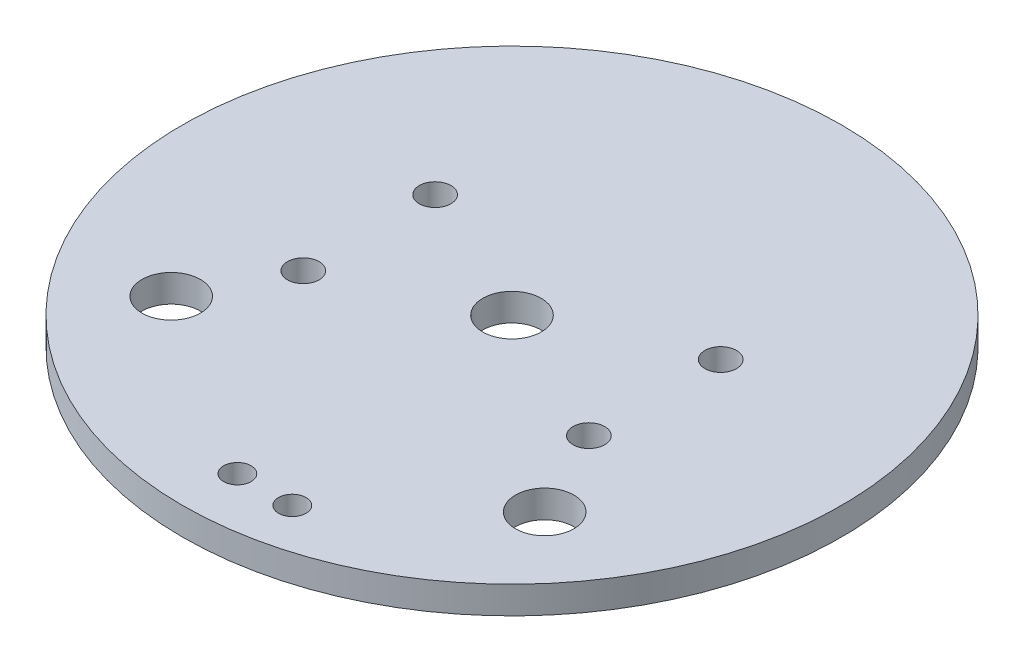
from build123d import *

# Parameters (mm, degrees)
SKETCH1_R                    = 38.1
BOSS_EXTRUDE1_DEPTH          = 1.5875
F_1_4_CLEARANCE_HOLE1_D      = 6.7564
F_1_4_CLEARANCE_HOLE2_D      = 6.7564
F_1_8_0_125_DIAMETER_HOLE1_D = 3.175
F_27_0_144_DIAMETER_HOLE1_D  = 3.6576


with BuildPart() as part:
    # Sketch1 → Boss-Extrude1 (new body, symmetric)
    with BuildSketch(Plane(origin=(0, 0, 0), x_dir=(1, 0, 0), z_dir=(0, 1, 0))):
        Circle(SKETCH1_R)
    extrude(amount=BOSS_EXTRUDE1_DEPTH, both=True)

    # 1/4 Clearance Hole1 (through all)
    with Locations(Plane(origin=(0, 1.5875, 0), x_dir=(1, 0, 0), z_dir=(0, 1, 0))):
        with Locations((-21.59, -17.810706314), (21.59, -17.810706314)):
            Hole(F_1_4_CLEARANCE_HOLE1_D / 2)

    # 1/4 Clearance Hole2 (through all)
    with Locations(Plane(origin=(0, 1.5875, 0), x_dir=(1, 0, 0), z_dir=(0, 1, 0))):
        with Locations((0, 0)):
            Hole(F_1_4_CLEARANCE_HOLE2_D / 2)

    # 1/8 (0.125) Diameter Hole1 (through all)
    with Locations(Plane(origin=(0, 1.5875, 0), x_dir=(1, 0, 0), z_dir=(0, 1, 0))):
        with Locations((0, -31.75), (6.35, -31.75)):
            Hole(F_1_8_0_125_DIAMETER_HOLE1_D / 2)

    # #27 (0.144) Diameter Hole1 (through all)
    with Locations(Plane(origin=(0, 1.5875, 0), x_dir=(1, 0, 0), z_dir=(0, 1, 0))):
        with Locations((-16.51, 7.62), (16.51, 7.62), (16.51, -7.62), (-16.51, -7.62)):
            Hole(F_27_0_144_DIAMETER_HOLE1_D / 2)


solid = part.part
